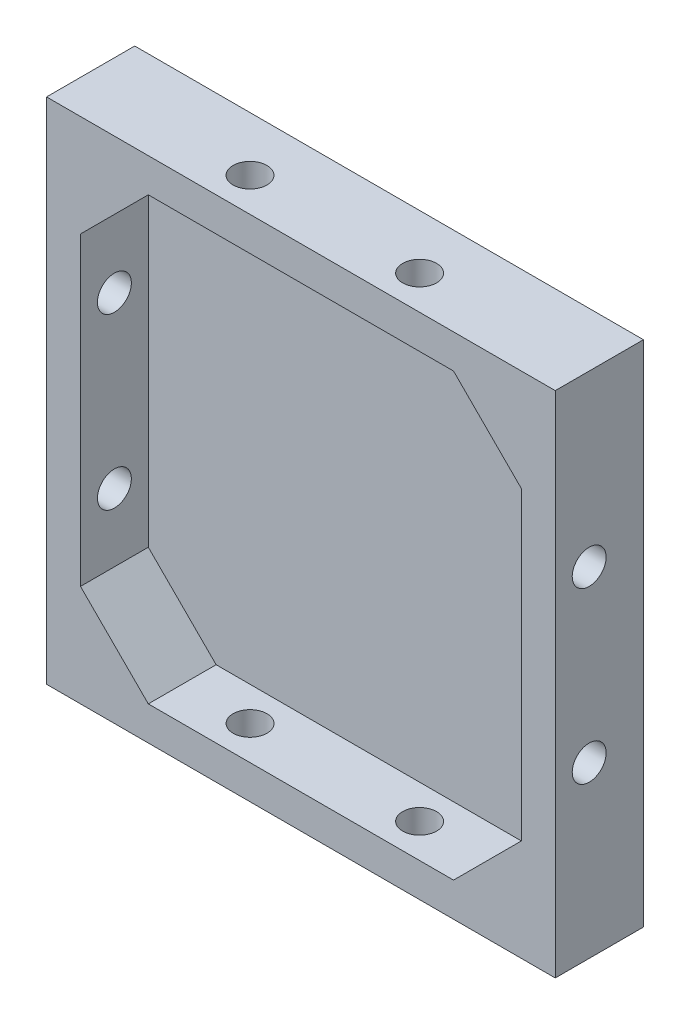
from build123d import *

# Parameters (mm, degrees)
BOSS_EXTRU_1_DEPTH        = 13
COQUE1_T                  = -5
COQUE1_THICKNESS_2_FACE_W = 65
COQUE1_THICKNESS_2_FACE_H = 65
COQUE1_THICKNESS_2_DEPTH  = 2
ENL_V_MAT_EXTRU_1_REACH   = 88.587
ESQUISSE2_R               = 2.5
ENL_V_MAT_EXTRU_2_REACH   = 95.396
ESQUISSE3_R               = 2.5
BOSS_EXTRU_2_DEPTH        = 10


with BuildPart() as part:
    # Esquisse1 → Boss.-Extru.1 (new body)
    with BuildSketch(Plane.XY):
        Polygon((44.118436308, 33.728448276), (54.118436308, 33.728448276), (54.118436308, 23.728448276), (54.118436308, -41.271551724), (-20.881563692, -41.271551724), (-20.881563692, 33.728448276), align=None)
    extrude(amount=BOSS_EXTRU_1_DEPTH)

    # Coque1
    coque1_openings = [part.faces().sort_by_distance(p)[0] for p in [
        (16.618436308, -3.771551724, 13),
    ]]
    offset(amount=COQUE1_T, openings=coque1_openings, kind=Kind.INTERSECTION)

    # Coque1 thickness 2 face (on inner face of the shell) → Coque1 thickness 2 (cut)
    with BuildSketch(Plane(origin=(16.618436308, -3.771551724, 5), x_dir=(-1, 0, 0), z_dir=(0, 0, -1))):
        Rectangle(COQUE1_THICKNESS_2_FACE_W, COQUE1_THICKNESS_2_FACE_H)
    extrude(amount=COQUE1_THICKNESS_2_DEPTH, mode=Mode.SUBTRACT)

    # Enlèv. mat.-Extru.1: up to this face of the body (flat: up to its plane)
    enl_v_mat_extru_1_end = Plane(part.part.faces().sort_by_distance((54.118436308, -3.771551724, 6.5))[0])
    # Esquisse2 → Enlèv. mat.-Extru.1 (cut, up to the picked face)
    with BuildSketch(Plane.ZY.offset(20.881563692), mode=Mode.PRIVATE) as enl_v_mat_extru_1_sk1:
        with Locations(Location((8, -16.271551724, 0), (0, 0, 270))):
            Circle(ESQUISSE2_R)
    enl_v_mat_extru_1_tool1 = split(extrude(enl_v_mat_extru_1_sk1.sketch, amount=-ENL_V_MAT_EXTRU_1_REACH, mode=Mode.PRIVATE), bisect_by=enl_v_mat_extru_1_end, keep=Keep.BOTH, mode=Mode.PRIVATE)
    # Esquisse2 → Enlèv. mat.-Extru.1 (cut, up to the picked face)
    with BuildSketch(Plane.ZY.offset(20.881563692), mode=Mode.PRIVATE) as enl_v_mat_extru_1_sk2:
        with Locations(Location((8, 8.728448276, 0), (0, 0, 270))):
            Circle(ESQUISSE2_R)
    enl_v_mat_extru_1_tool2 = split(extrude(enl_v_mat_extru_1_sk2.sketch, amount=-ENL_V_MAT_EXTRU_1_REACH, mode=Mode.PRIVATE), bisect_by=enl_v_mat_extru_1_end, keep=Keep.BOTH, mode=Mode.PRIVATE)
    add(enl_v_mat_extru_1_tool1.solids().sort_by(Axis((-20.881564, -16.271552, 8), (1, 0, 0)))[0], mode=Mode.SUBTRACT)
    add(enl_v_mat_extru_1_tool2.solids().sort_by(Axis((-20.881564, 8.728448, 8), (1, 0, 0)))[0], mode=Mode.SUBTRACT)

    # Enlèv. mat.-Extru.2: up to this face of the body (flat: up to its plane)
    enl_v_mat_extru_2_end = Plane(part.part.faces().sort_by_distance((16.618436308, 33.728448276, 6.5))[0])
    # Esquisse3 → Enlèv. mat.-Extru.2 (cut, up to the picked face)
    with BuildSketch(Plane.XZ.offset(41.271551724), mode=Mode.PRIVATE) as enl_v_mat_extru_2_sk1:
        with Locations(Location((4.118436308, 8, 0), (0, 0, 270))):
            Circle(ESQUISSE3_R)
    enl_v_mat_extru_2_tool1 = split(extrude(enl_v_mat_extru_2_sk1.sketch, amount=-ENL_V_MAT_EXTRU_2_REACH, mode=Mode.PRIVATE), bisect_by=enl_v_mat_extru_2_end, keep=Keep.BOTH, mode=Mode.PRIVATE)
    # Esquisse3 → Enlèv. mat.-Extru.2 (cut, up to the picked face)
    with BuildSketch(Plane.XZ.offset(41.271551724), mode=Mode.PRIVATE) as enl_v_mat_extru_2_sk2:
        with Locations(Location((29.118436308, 8, 0), (0, 0, 270))):
            Circle(ESQUISSE3_R)
    enl_v_mat_extru_2_tool2 = split(extrude(enl_v_mat_extru_2_sk2.sketch, amount=-ENL_V_MAT_EXTRU_2_REACH, mode=Mode.PRIVATE), bisect_by=enl_v_mat_extru_2_end, keep=Keep.BOTH, mode=Mode.PRIVATE)
    add(enl_v_mat_extru_2_tool1.solids().sort_by(Axis((4.118436, -41.271552, 8), (0, 1, 0)))[0], mode=Mode.SUBTRACT)
    add(enl_v_mat_extru_2_tool2.solids().sort_by(Axis((29.118436, -41.271552, 8), (0, 1, 0)))[0], mode=Mode.SUBTRACT)

    # Esquisse4 → Boss.-Extru.2 (add)
    with BuildSketch(Plane.XY.offset(3)):
        Polygon((-5.881563692, 28.728448276), (-15.881563692, 18.728448276), (-15.881563692, 28.728448276), align=None)
        Polygon((49.118436308, 28.728448276), (49.118436308, 18.728448276), (39.118436308, 28.728448276), align=None)
        Polygon((49.118436308, -36.271551724), (49.118436308, -26.271551724), (39.118436308, -36.271551724), align=None)
        Polygon((-5.881563692, -36.271551724), (-15.881563692, -26.271551724), (-15.881563692, -36.271551724), align=None)
    extrude(amount=BOSS_EXTRU_2_DEPTH)


solid = part.part
